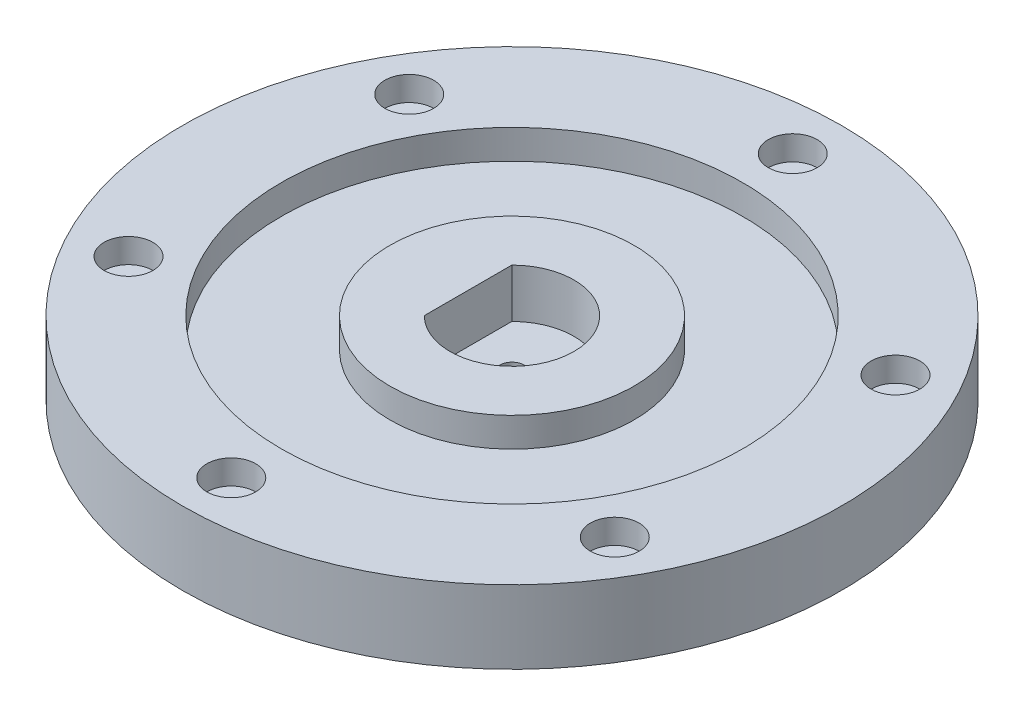
from build123d import *

# Parameters (mm, degrees)
SKETCH1_R           = 67.5
BOSS_EXTRUDE1_DEPTH = 15
SKETCH2_R           = 47.25
SKETCH2_R_2         = 25
CUT_EXTRUDE1_DEPTH  = 6
CUT_EXTRUDE2_DEPTH  = 10
SKETCH5_R           = 2.5
CUT_EXTRUDE3_DEPTH  = 10
SKETCH6_R           = 2
CUT_EXTRUDE4_DEPTH  = 15
SKETCH7_R           = 5
CUT_EXTRUDE5_DEPTH  = 5
SKETCH8_R           = 2
CUT_EXTRUDE6_DEPTH  = 10


with BuildPart() as part:
    # Sketch1 → Boss-Extrude1 (new body)
    with BuildSketch(Plane(origin=(0, 0, 0), x_dir=(1, 0, 0), z_dir=(0, 1, 0))):
        Circle(SKETCH1_R)
    extrude(amount=BOSS_EXTRUDE1_DEPTH)

    # Sketch2 → Cut-Extrude1 (cut)
    with BuildSketch(Plane(origin=(0, 15, 0), x_dir=(1, 0, 0), z_dir=(0, 1, 0))):
        Circle(SKETCH2_R)
        Circle(SKETCH2_R_2, mode=Mode.SUBTRACT)
    extrude(amount=-CUT_EXTRUDE1_DEPTH, mode=Mode.SUBTRACT)

    # Sketch3 → Cut-Extrude2 (cut)
    with BuildSketch(Plane(origin=(0, 15, 0), x_dir=(1, 0, 0), z_dir=(0, 1, 0))):
        with BuildLine():
            Line((-9, 8.960468738), (-9, -8.960468738))
            ThreePointArc((-9, -8.960468738), (12.7, 0), (-9, 8.960468738))
        make_face()
    extrude(amount=-CUT_EXTRUDE2_DEPTH, mode=Mode.SUBTRACT)

    # Sketch5 → Cut-Extrude3 (cut)
    with BuildSketch(Plane(origin=(0, 5, 0), x_dir=(1, 0, 0), z_dir=(0, 1, 0))):
        Circle(SKETCH5_R)
    extrude(amount=-CUT_EXTRUDE3_DEPTH, mode=Mode.SUBTRACT)

    # Sketch6 → Cut-Extrude4 (cut)
    with BuildSketch(Plane(origin=(0, 15, 0), x_dir=(1, 0, 0), z_dir=(0, 1, 0))):
        with Locations((0, 57.5)):
            Circle(SKETCH6_R)
        with Locations((49.796460718, 28.75)):
            Circle(SKETCH6_R)
        with Locations((49.796460718, -28.75)):
            Circle(SKETCH6_R)
        with Locations((0, -57.5)):
            Circle(SKETCH6_R)
        with Locations((-49.796460718, -28.75)):
            Circle(SKETCH6_R)
        with Locations((-49.796460718, 28.75)):
            Circle(SKETCH6_R)
    extrude(amount=-CUT_EXTRUDE4_DEPTH, mode=Mode.SUBTRACT)

    # Sketch7 → Cut-Extrude5 (cut)
    with BuildSketch(Plane(origin=(0, 15, 0), x_dir=(1, 0, 0), z_dir=(0, 1, 0))):
        with Locations((0, 57.5)):
            Circle(SKETCH7_R)
        with Locations((49.796460718, 28.75)):
            Circle(SKETCH7_R)
        with Locations((49.796460718, -28.75)):
            Circle(SKETCH7_R)
        with Locations((0, -57.5)):
            Circle(SKETCH7_R)
        with Locations((-49.796460718, -28.75)):
            Circle(SKETCH7_R)
        with Locations((-49.796460718, 28.75)):
            Circle(SKETCH7_R)
    extrude(amount=-CUT_EXTRUDE5_DEPTH, mode=Mode.SUBTRACT)

    # Sketch8 → Cut-Extrude6 (cut)
    with BuildSketch(Plane.XZ):
        with Locations((-25, 45)):
            Circle(SKETCH8_R)
        with Locations((-45, 45)):
            Circle(SKETCH8_R)
        with Locations((25, 45)):
            Circle(SKETCH8_R)
        with Locations((45, 45)):
            Circle(SKETCH8_R)
        with Locations((45, -45)):
            Circle(SKETCH8_R)
        with Locations((25, -45)):
            Circle(SKETCH8_R)
        with Locations((-25, -45)):
            Circle(SKETCH8_R)
        with Locations((-45, -45)):
            Circle(SKETCH8_R)
    extrude(amount=-CUT_EXTRUDE6_DEPTH, mode=Mode.SUBTRACT)


solid = part.part
